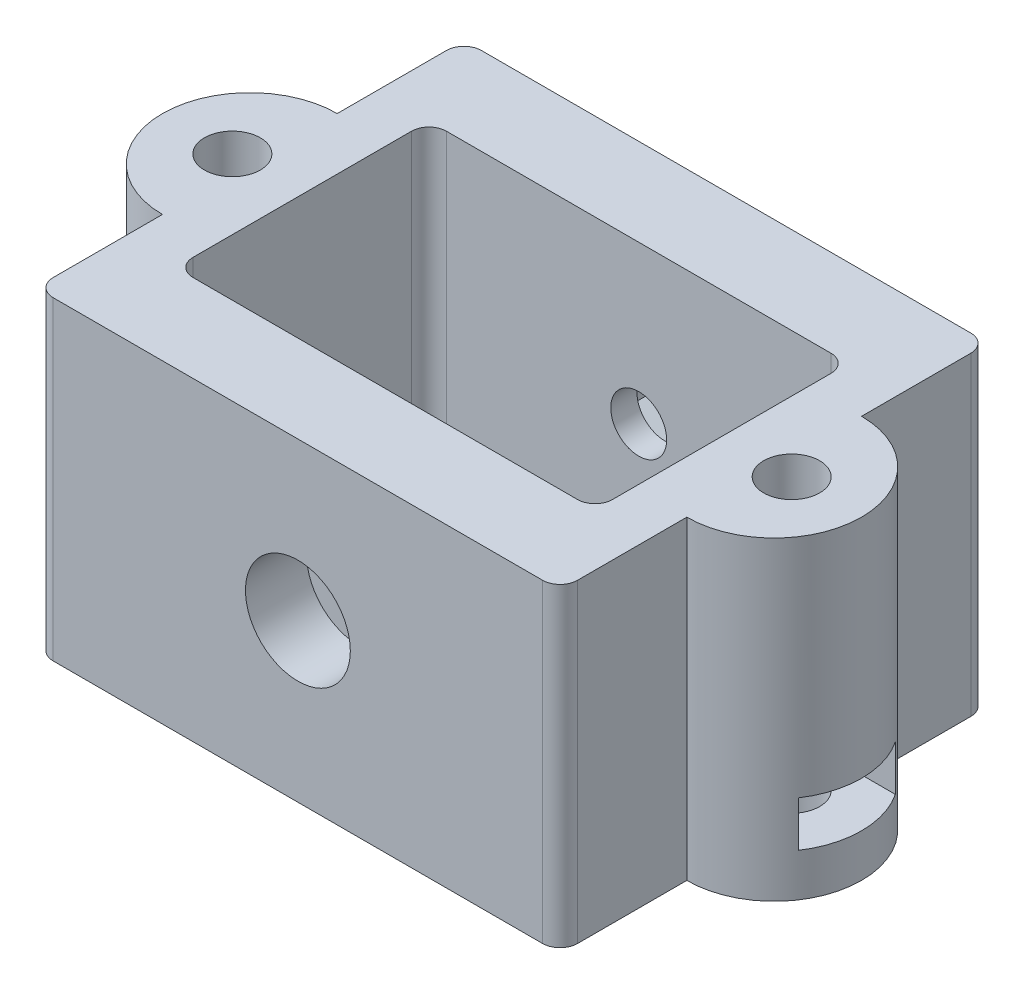
from build123d import *

# Parameters (mm, degrees)
SKETCH1_W           = 24
SKETCH1_H           = 14.5
BOSS_EXTRUDE1_DEPTH = 18
SKETCH2_R           = 1.6
CUT_EXTRUDE1_DEPTH  = 19
SKETCH3_R           = 1.6
CUT_EXTRUDE2_DEPTH  = 25.5
SKETCH4_R           = 3
CUT_EXTRUDE3_DEPTH  = 3.5
CUT_EXTRUDE4_DEPTH  = 3.5
FILLET1_R           = 1
CUT_EXTRUDE5_DEPTH  = 2.6


with BuildPart() as part:
    # Sketch1 → Boss-Extrude1 (new body)
    with BuildSketch(Plane(origin=(0, 0, 0), x_dir=(1, 0, 0), z_dir=(0, 1, 0))):
        with BuildLine():
            Line((0, 0), (30, 0))
            Line((30, 0), (30, 7.25))
            ThreePointArc((30, 7.25), (35, 12.25), (30, 17.25))
            Line((30, 17.25), (30, 24.5))
            Line((30, 24.5), (0, 24.5))
            Line((0, 24.5), (0, 17.25))
            ThreePointArc((0, 17.25), (-5, 12.25), (0, 7.25))
            Line((0, 7.25), (0, 0))
        make_face()
        with Locations((15, 12.25)):
            Rectangle(SKETCH1_W, SKETCH1_H, mode=Mode.SUBTRACT)
    extrude(amount=BOSS_EXTRUDE1_DEPTH)

    # Sketch2 → Cut-Extrude1 (cut, through all)
    with BuildSketch(Plane.XZ):
        with Locations((31, -12.25)):
            Circle(SKETCH2_R)
        with Locations((-1, -12.25)):
            Circle(SKETCH2_R)
    extrude(amount=-CUT_EXTRUDE1_DEPTH, mode=Mode.SUBTRACT)

    # Sketch3 → Cut-Extrude2 (cut, through all)
    with BuildSketch(Plane(origin=(0, 0, -24.5), x_dir=(-1, 0, 0), z_dir=(0, 0, -1))):
        with Locations((-15, 9)):
            Circle(SKETCH3_R)
    extrude(amount=-CUT_EXTRUDE2_DEPTH, mode=Mode.SUBTRACT)

    # Sketch4 → Cut-Extrude3 (cut)
    with BuildSketch(Plane.XY):
        with Locations((15, 9)):
            Circle(SKETCH4_R)
    extrude(amount=-CUT_EXTRUDE3_DEPTH, mode=Mode.SUBTRACT)

    # Sketch5 → Cut-Extrude4 (cut)
    with BuildSketch(Plane(origin=(0, 0, -24.5), x_dir=(-1, 0, 0), z_dir=(0, 0, -1))):
        Polygon((-12.228718708, 7.4), (-12.228718708, 10.6), (-15, 12.2), (-17.771281292, 10.6), (-17.771281292, 7.4), (-15, 5.8), align=None)
    extrude(amount=-CUT_EXTRUDE4_DEPTH, mode=Mode.SUBTRACT)

    # Fillet1
    fillet1_edges = [part.edges().sort_by_distance(p)[0] for p in [
        (0, 9, -24.5),
        (30, 9, -24.5),
        (30, 9, 0),
        (0, 9, 0),
        (27, 9, -5),
        (27, 9, -19.5),
        (3, 9, -19.5),
        (3, 9, -5),
    ]]
    fillet(fillet1_edges, radius=FILLET1_R)

    # Sketch6 → Cut-Extrude5 (cut)
    with BuildSketch(Plane(origin=(0, 2.46, 0), x_dir=(-1, 0, 0), z_dir=(0, -1, 0))):
        Polygon((-32.6, 15.021281292), (-42.6, 15.021281292), (-42.6, 9.478718708), (-32.6, 9.478718708), (-29.4, 9.478718708), (-27.8, 12.25), (-29.4, 15.021281292), align=None)
        Polygon((-0.6, 15.021281292), (2.6, 15.021281292), (12.6, 15.021281292), (12.6, 9.478718708), (2.6, 9.478718708), (-0.6, 9.478718708), (-2.2, 12.25), align=None)
    extrude(amount=-CUT_EXTRUDE5_DEPTH, mode=Mode.SUBTRACT)


solid = part.part
